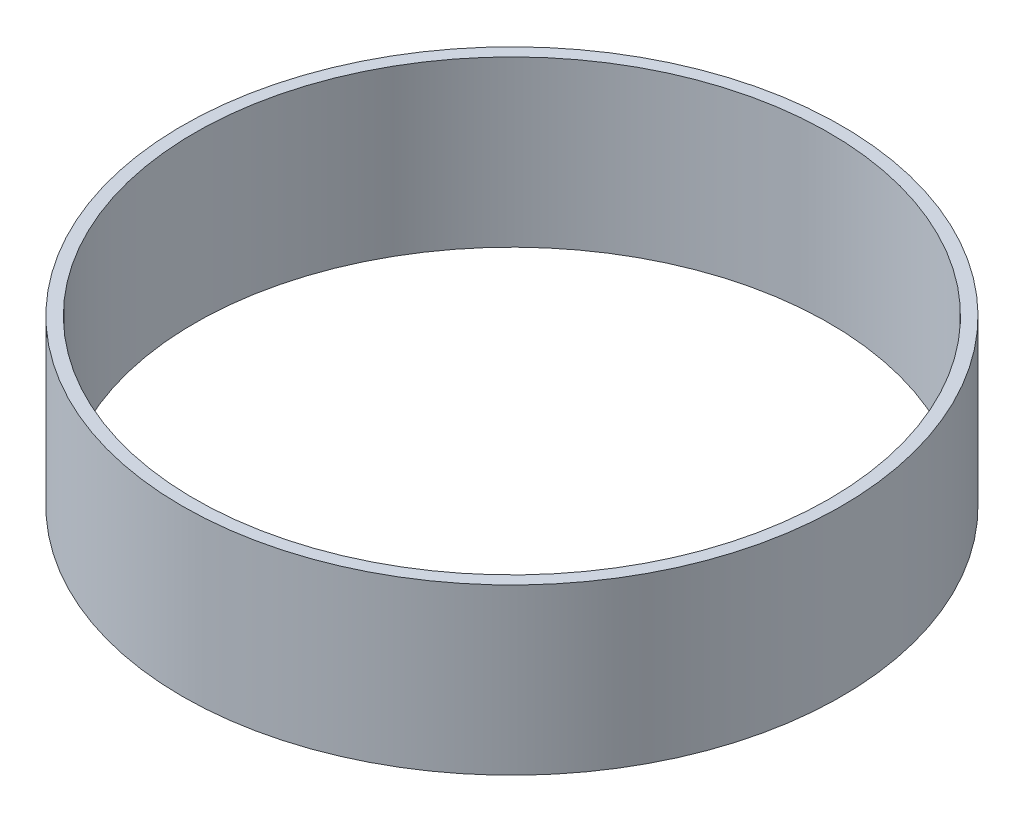
from build123d import *

# Parameters (mm, degrees)
SKETCH_1_R      = 80
SKETCH_1_R_2    = 77
EXTRUDE_1_DEPTH = 40


with BuildPart() as part:
    # Эскиз1 → Вытянуть-Тонкостенный1 (new body)
    with BuildSketch(Plane(origin=(0, 0, 0), x_dir=(1, 0, 0), z_dir=(0, 1, 0))):
        Circle(SKETCH_1_R)
        Circle(SKETCH_1_R_2, mode=Mode.SUBTRACT)
    extrude(amount=EXTRUDE_1_DEPTH)


solid = part.part
